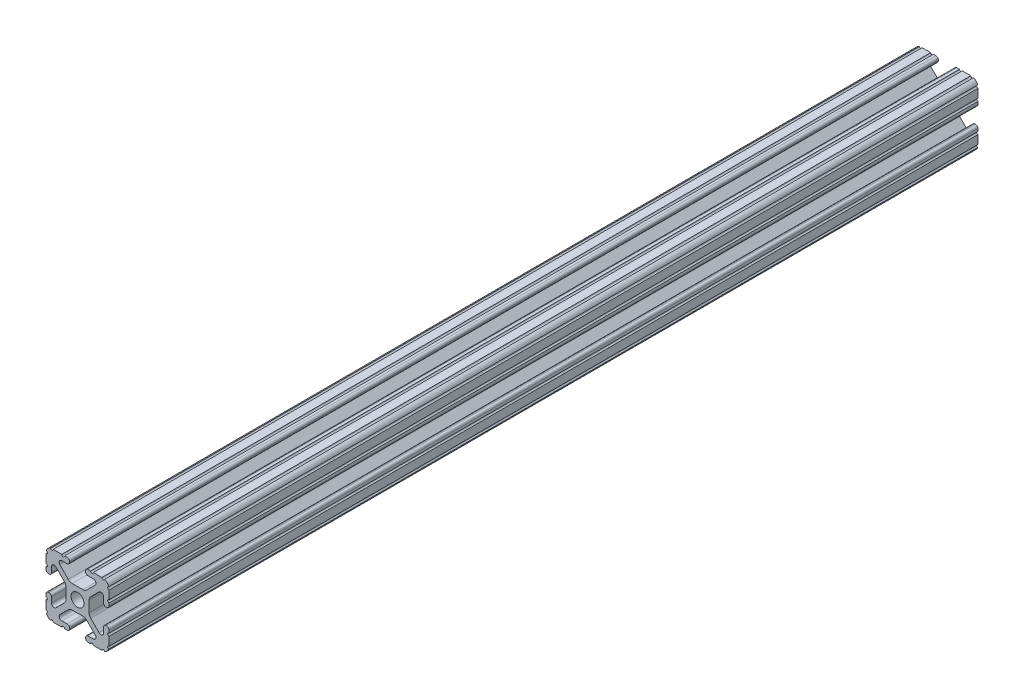
from build123d import *

# Parameters (mm, degrees)
BOSS_EXTRUDE1_DEPTH     = 175
SKETCH5_R               = 0.55245
CUT_EXTRUDE1_DEPTH      = 176
CUT_EXTRUDE1_DEPTH_BACK = 176
SKETCH6_R               = 2.555
CUT_EXTRUDE2_DEPTH      = 13.7
CUT_EXTRUDE2_DEPTH_BACK = 13.7


with BuildPart() as part:
    # Sketch4 → Boss-Extrude1 (new body, symmetric)
    with BuildSketch(Plane.XY):
        with BuildLine():
            Line((4.190365, -12.7), (10.11729625, -12.7))
            ThreePointArc((10.11729625, -12.7), (11.943543585, -11.943543585), (12.7, -10.11729625))
            Line((12.7, -10.11729625), (12.7, -4.190365))
            ThreePointArc((12.7, -4.190365), (12.42492494, -3.52627506), (11.760835, -3.2512))
            Line((11.760835, -3.2512), (11.429365, -3.2512))
            ThreePointArc((11.429365, -3.2512), (10.76527506, -3.52627506), (10.4902, -4.190365))
            Line((10.4902, -4.190365), (10.4902, -6.348478019))
            ThreePointArc((10.4902, -6.348478019), (9.830707141, -7.335478831), (8.666460301, -7.103895736))
            Line((8.666460301, -7.103895736), (5.299899128, -3.737334563))
            ThreePointArc((5.299899128, -3.737334563), (4.817571085, -3.015479634), (4.6482, -2.16399369))
            Line((4.6482, -2.16399369), (4.6482, 0))
            Line((4.6482, 0), (2.6035, 0))
            ThreePointArc((2.6035, 0), (1.840952505, -1.840952505), (0, -2.6035))
            Line((0, -2.6035), (0, -4.6482))
            Line((0, -4.6482), (2.16399369, -4.6482))
            ThreePointArc((2.16399369, -4.6482), (3.015479634, -4.817571085), (3.737334563, -5.299899128))
            Line((3.737334563, -5.299899128), (7.103895736, -8.666460301))
            ThreePointArc((7.103895736, -8.666460301), (7.335478831, -9.830707141), (6.348478019, -10.4902))
            Line((6.348478019, -10.4902), (4.190365, -10.4902))
            ThreePointArc((4.190365, -10.4902), (3.52627506, -10.76527506), (3.2512, -11.429365))
            Line((3.2512, -11.429365), (3.2512, -11.760835))
            ThreePointArc((3.2512, -11.760835), (3.52627506, -12.42492494), (4.190365, -12.7))
        make_face()
    extrude(amount=BOSS_EXTRUDE1_DEPTH, both=True)

    # Sketch5 → Cut-Extrude1 (cut, two sides)
    with BuildSketch(Plane.XY) as cut_extrude1_sk:
        with Locations((10.356153152, -12.7)):
            Circle(SKETCH5_R)
        with Locations((5.796028019, -12.7)):
            Circle(SKETCH5_R)
        with Locations((12.7, -10.356153152)):
            Circle(SKETCH5_R)
        with Locations((12.7, -5.796028019)):
            Circle(SKETCH5_R)
    extrude(amount=CUT_EXTRUDE1_DEPTH, mode=Mode.SUBTRACT)
    extrude(cut_extrude1_sk.sketch, amount=-CUT_EXTRUDE1_DEPTH_BACK, mode=Mode.SUBTRACT)

    # Mirror1: part across plane


with BuildPart() as part_1:
    add(part.part)
    add(part.part.mirror(Plane(origin=(0, 0, 0), x_dir=(0, 0, 1), z_dir=(1, 0, 0))))

    # Mirror2: part across plane


with BuildPart() as part_2:
    add(part_1.part)
    add(part_1.part.mirror(Plane.ZX))

    # Sketch6 → Cut-Extrude2 (cut, two sides)
    with BuildSketch(Plane(origin=(0, 0, 0), x_dir=(1, 0, 0), z_dir=(0, 1, 0))) as cut_extrude2_sk:
        with Locations((0, -162.3)):
            Circle(SKETCH6_R)
        with Locations((0, 162.3)):
            Circle(SKETCH6_R)
    extrude(amount=CUT_EXTRUDE2_DEPTH, mode=Mode.SUBTRACT)
    extrude(cut_extrude2_sk.sketch, amount=-CUT_EXTRUDE2_DEPTH_BACK, mode=Mode.SUBTRACT)


solid = part_2.part
